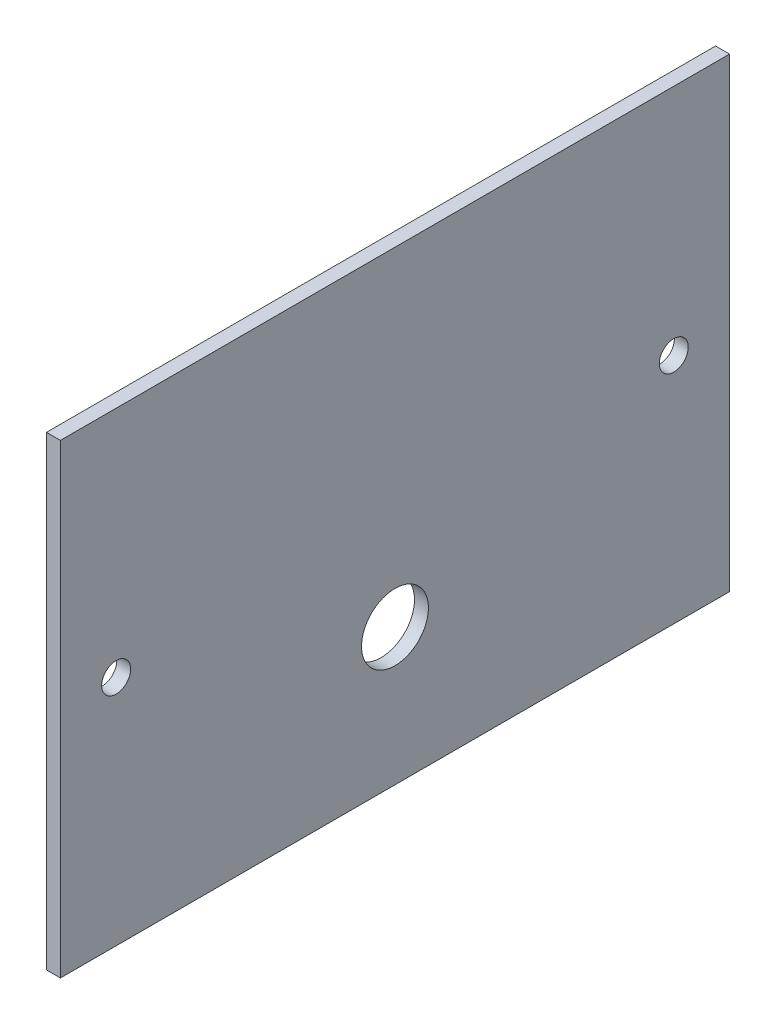
from build123d import *

# Parameters (mm, degrees)
SKETCH1_W           = 152.4
SKETCH1_H           = 106.045
BOSS_EXTRUDE1_DEPTH = 3.175
SKETCH2_R           = 7.62
SKETCH2_R_2         = 3.302
CUT_EXTRUDE1_DEPTH  = 4.175


with BuildPart() as part:
    # Sketch1 → Boss-Extrude1 (new body)
    with BuildSketch(Plane(origin=(0, 0, 0), x_dir=(0, 0, -1), z_dir=(1, 0, 0))):
        with Locations((76.2, 53.0225)):
            Rectangle(SKETCH1_W, SKETCH1_H)
    extrude(amount=BOSS_EXTRUDE1_DEPTH)

    # Sketch2 → Cut-Extrude1 (cut, through all)
    with BuildSketch(Plane(origin=(3.175, 0, 0), x_dir=(0, 0, -1), z_dir=(1, 0, 0))):
        with Locations((76.2, 31.115)):
            Circle(SKETCH2_R)
        with Locations((12.7, 52.959)):
            Circle(SKETCH2_R_2)
        with Locations((139.7, 52.959)):
            Circle(SKETCH2_R_2)
    extrude(amount=-CUT_EXTRUDE1_DEPTH, mode=Mode.SUBTRACT)


solid = part.part
